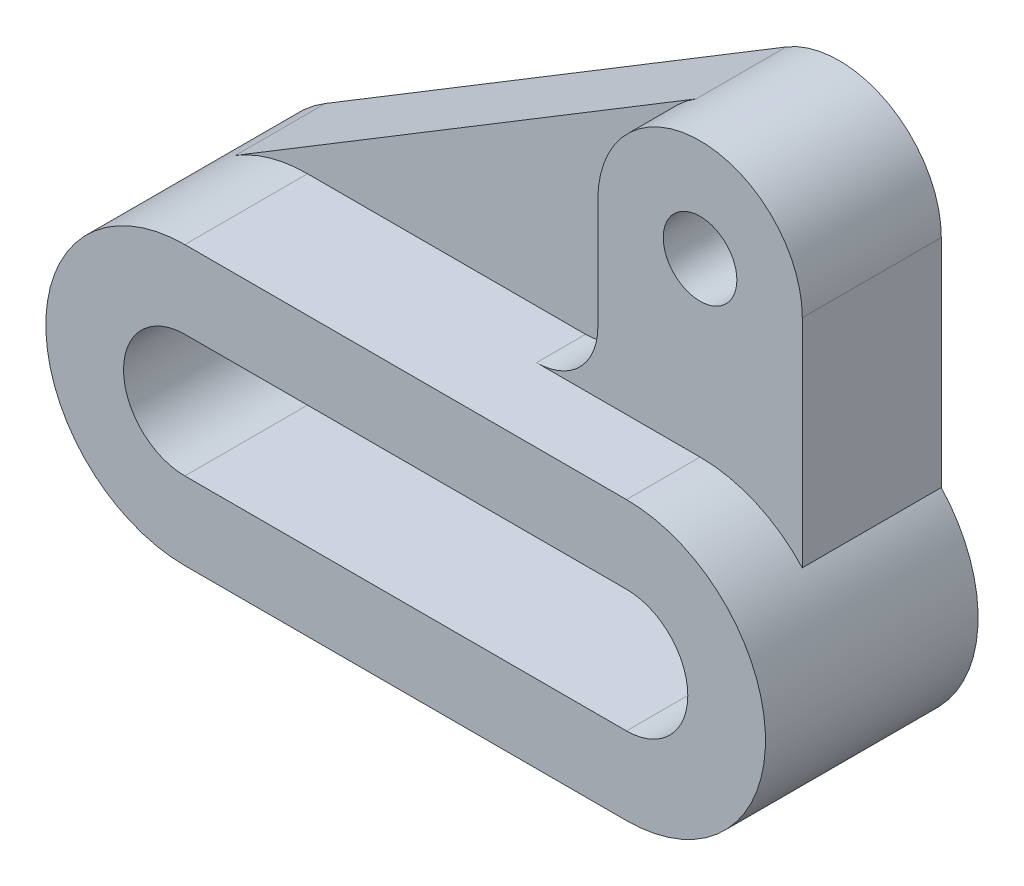
from build123d import *

# Parameters (mm, degrees)
Y_KSEKLIK_EKSTR_ZYON1_DEPTH = 52
IZIM3_R                     = 9
Y_KSEKLIK_EKSTR_ZYON2_DEPTH = 34
FEDER1_REACH                = 139.277
IZIM4_WALL_W                = 408.307741914
IZIM4_WALL_H                = 22


with BuildPart() as part:
    # Çizim1 → Yükseklik-Ekstrüzyon1 (new body)
    with BuildSketch(Plane.XY):
        with BuildLine():
            Line((-54, 34), (54, 34))
            ThreePointArc((54, 34), (88, 0), (54, -34))
            Line((54, -34), (-54, -34))
            ThreePointArc((-54, -34), (-88, 0), (-54, 34))
        make_face()
        with BuildLine():
            Line((-54, 15), (54, 15))
            ThreePointArc((54, 15), (69, 0), (54, -15))
            Line((54, -15), (-54, -15))
            ThreePointArc((-54, -15), (-69, 0), (-54, 15))
        make_face(mode=Mode.SUBTRACT)
    extrude(amount=-Y_KSEKLIK_EKSTR_ZYON1_DEPTH)

    # Çizim3 → Yükseklik-Ekstrüzyon2 (add)
    with BuildSketch(Plane.XY.offset(-18)):
        with BuildLine():
            ThreePointArc((79, 76), (54, 101), (29, 76))
            Line((29, 76), (29, 49))
            ThreePointArc((29, 49), (24.606601718, 38.393398282), (14, 34))
            Line((14, 34), (54, 34))
            ThreePointArc((54, 34), (67.647767834, 31.140623519), (79, 23.043437244))
            Line((79, 23.043437244), (79, 76))
        make_face()
        with Locations((54, 76)):
            Circle(IZIM3_R, mode=Mode.SUBTRACT)
    extrude(amount=-Y_KSEKLIK_EKSTR_ZYON2_DEPTH)

    # Çizim4 wall → Feder1 (add, up to next)
    with BuildSketch(Plane(origin=(-15.293433294, 63.226194681, -30), x_dir=(0.855125243419, 0.518421467599, 0), z_dir=(-0.518421467599, 0.855125243419, 0)), mode=Mode.PRIVATE) as feder1_sk1:
        with Locations((0, 11)):
            Rectangle(IZIM4_WALL_W, IZIM4_WALL_H)
    feder1_tool1 = extrude(feder1_sk1.sketch, amount=-FEDER1_REACH, mode=Mode.PRIVATE) - part.part
    add(feder1_tool1.solids().sort_by_distance((-15.293433294, 63.226194681, -30))[0])


solid = part.part
